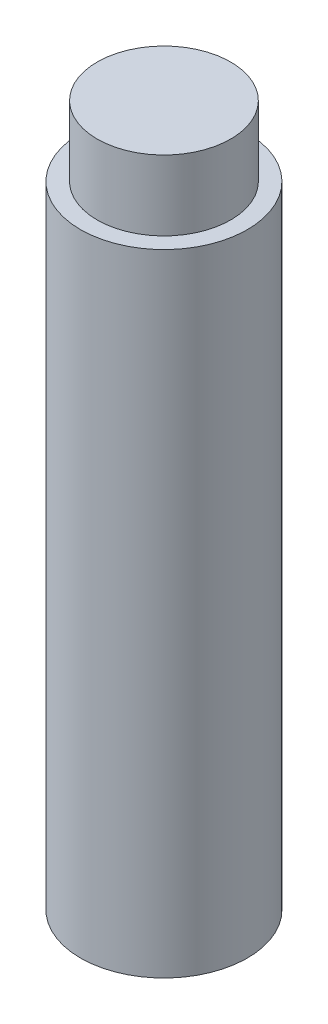
from build123d import *

# Parameters (mm, degrees)
SKETCH1_R           = 2.38125
BOSS_EXTRUDE1_DEPTH = 20
SKETCH2_R           = 2.38125
SKETCH2_R_2         = 1.905
CUT_EXTRUDE1_DEPTH  = 2


with BuildPart() as part:
    # Sketch1 → Boss-Extrude1 (new body)
    with BuildSketch(Plane(origin=(0, 0, 0), x_dir=(1, 0, 0), z_dir=(0, 1, 0))):
        Circle(SKETCH1_R)
    extrude(amount=BOSS_EXTRUDE1_DEPTH)

    # Sketch2 → Cut-Extrude1 (cut)
    with BuildSketch(Plane(origin=(0, 20, 0), x_dir=(1, 0, 0), z_dir=(0, 1, 0))):
        Circle(SKETCH2_R)
        Circle(SKETCH2_R_2, mode=Mode.SUBTRACT)
    extrude(amount=-CUT_EXTRUDE1_DEPTH, mode=Mode.SUBTRACT)


solid = part.part
